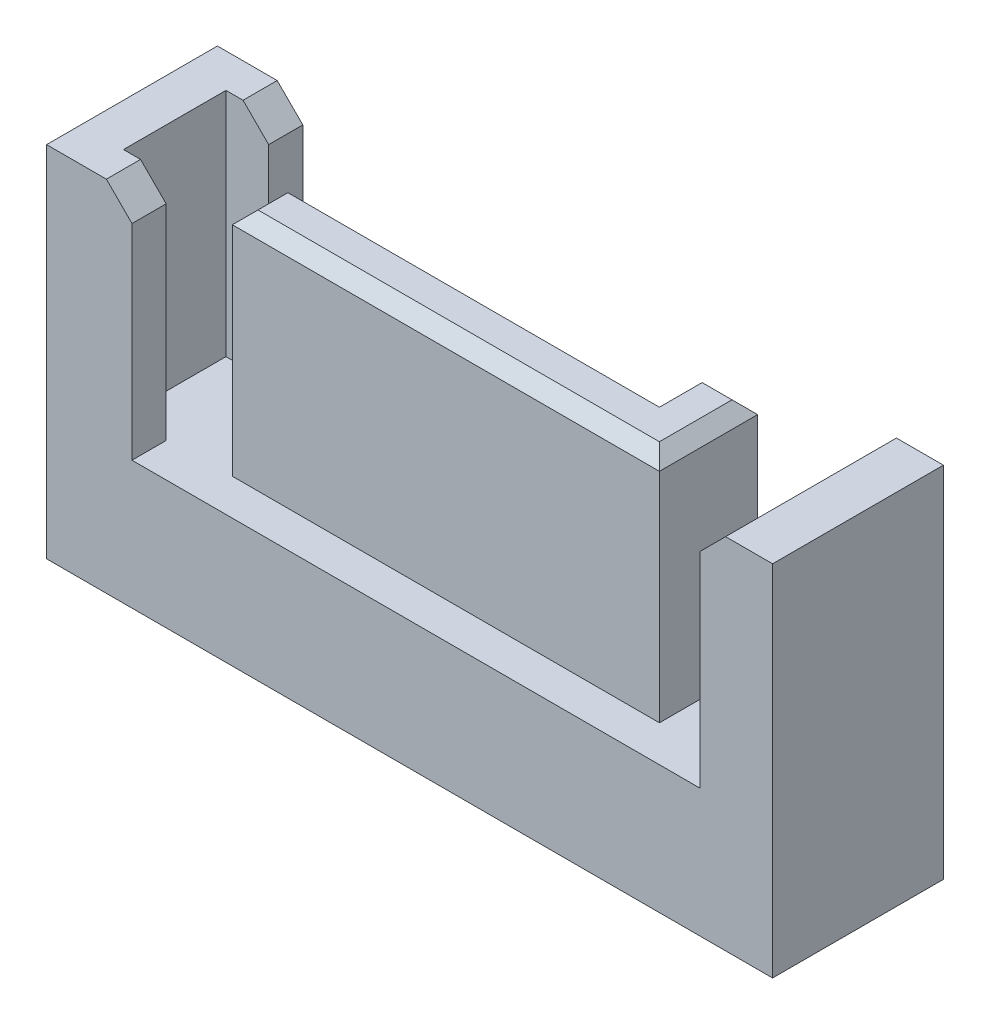
from build123d import *

# Parameters (mm, degrees)
CROQUIS1_W            = 17
CROQUIS1_H            = 4
EXTRUIR1_DEPTH        = 8.4
CORTAR_EXTRUIR1_DEPTH = 5.4
CHAFL_N1_SIZE         = 0.6
EXTRUIR2_DEPTH        = 5.4
CHAFL_N2_SIZE         = 0.3


with BuildPart() as part:
    # Croquis1 → Extruir1 (new body)
    with BuildSketch(Plane(origin=(0, 0, 0), x_dir=(1, 0, 0), z_dir=(0, 1, 0))):
        Rectangle(CROQUIS1_W, CROQUIS1_H)
    extrude(amount=EXTRUIR1_DEPTH)

    # Croquis2 → Cortar-Extruir1 (cut)
    with BuildSketch(Plane(origin=(0, 8.4, 0), x_dir=(-1, 0, 0), z_dir=(0, 1, 0))):
        Polygon((-6.8, -2), (6.5, -2), (6.5, -1.2), (7.5, -1.2), (7.5, 1.2), (6.5, 1.2), (6.5, 2), (-6.8, 2), align=None)
    extrude(amount=-CORTAR_EXTRUIR1_DEPTH, mode=Mode.SUBTRACT)

    # Chaflán1
    chafl_n1_edges = [part.edges().sort_by_distance(p)[0] for p in [
        (6.8, 8.4, 0),
        (-6.5, 8.4, -1.6),
        (-6.5, 8.4, 1.6),
    ]]
    chamfer(chafl_n1_edges, length=CHAFL_N1_SIZE)

    # Croquis3 → Extruir2 (add)
    with BuildSketch(Plane(origin=(0, 3, 0), x_dir=(-1, 0, 0), z_dir=(0, 1, 0))):
        Polygon((-5, -1.15), (-5, 1.15), (5, 1.15), (5, -0.15), (-3.7, -0.15), (-3.7, -1.15), align=None)
    extrude(amount=EXTRUIR2_DEPTH)

    # Chaflán2
    chafl_n2_edges = [part.edges().sort_by_distance(p)[0] for p in [
        (4.35, 8.4, -1.15),
        (3.7, 8.4, -0.65),
        (-0.65, 8.4, -0.15),
        (-5, 8.4, 0.5),
        (0, 8.4, 1.15),
        (5, 8.4, 0),
    ]]
    chamfer(chafl_n2_edges, length=CHAFL_N2_SIZE)


solid = part.part
